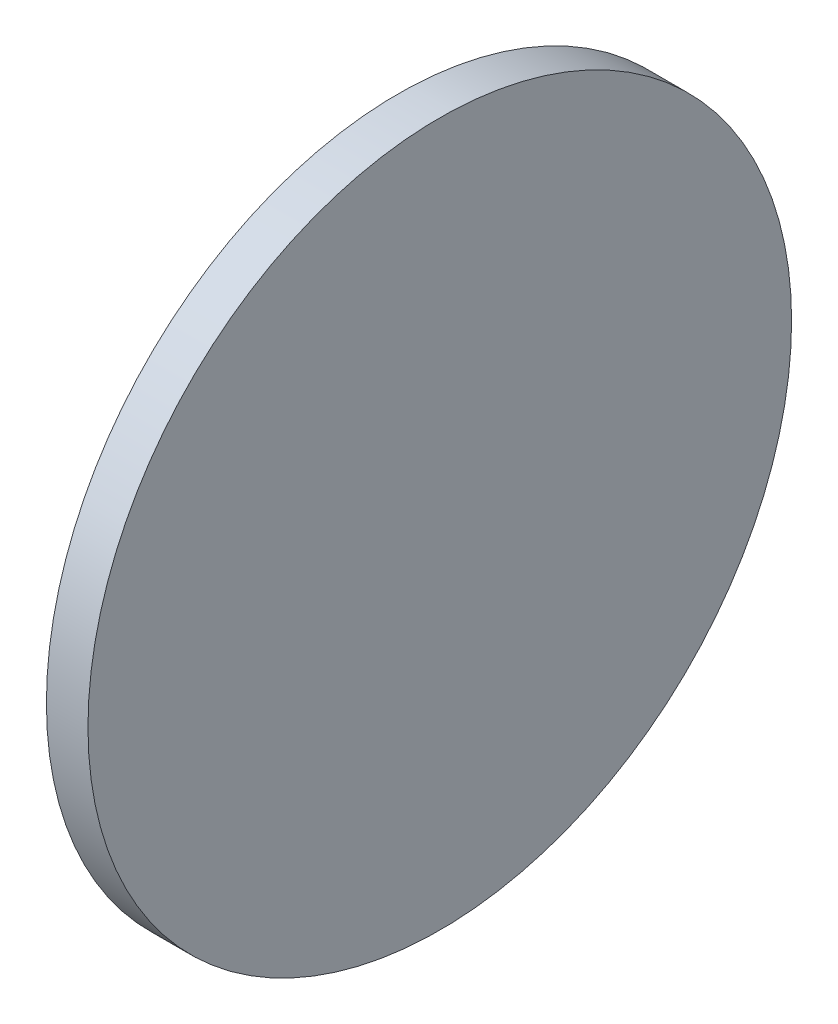
from build123d import *

# Parameters (mm, degrees)
SKETCH_1_W = 3
SKETCH_1_H = 25.4


with BuildPart() as part:
    # 草图1 → 旋转2 (revolve)
    with BuildSketch(Plane.XY, mode=Mode.PRIVATE) as revolve_2_sk:
        with Locations((1.5, 12.7)):
            Rectangle(SKETCH_1_W, SKETCH_1_H)
    revolve(revolve_2_sk.sketch.rotate(Axis((0, 0, 0), (1, 0, 0)), 90), axis=Axis((0, 0, 0), (1, 0, 0)))  # turned: the seam where the file's is


solid = part.part
